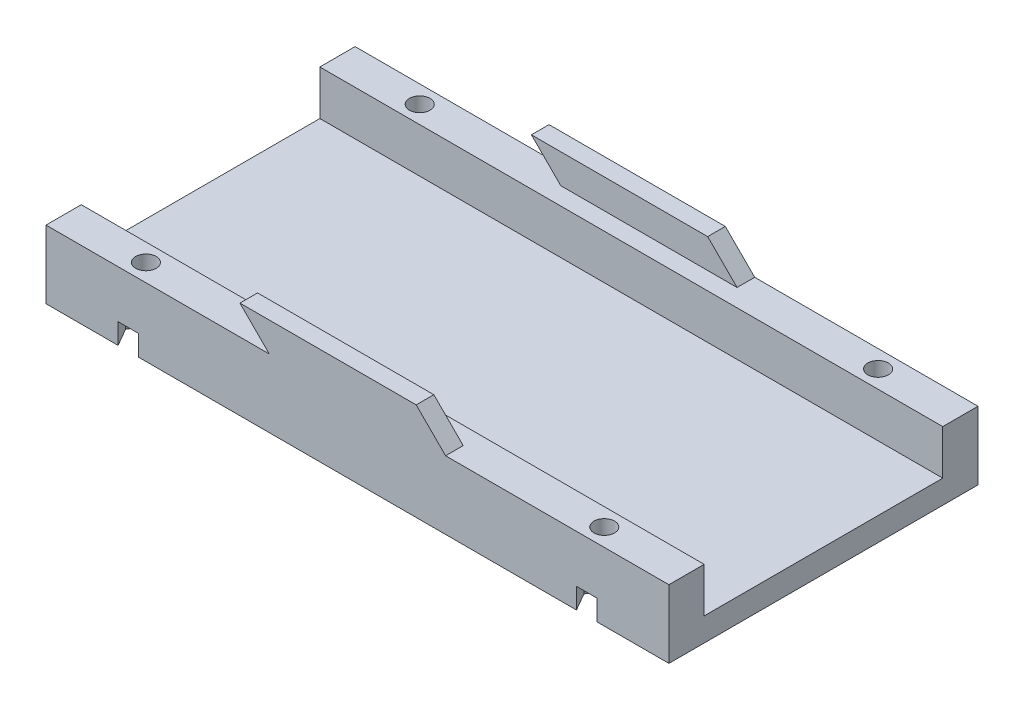
from build123d import *

# Parameters (mm, degrees)
SKETCH1_W           = 106
SKETCH1_H           = 6
SKETCH1_H_2         = 9.4
SKETCH1_H_3         = 8.5
SKETCH1_H_4         = 4.8
BOSS_EXTRUDE4_DEPTH = 4
SKETCH5_W           = 106
SKETCH5_H           = 6
BOSS_EXTRUDE5_DEPTH = 7.6
SKETCH4_W           = 106
SKETCH4_H           = 6
BOSS_EXTRUDE6_DEPTH = 7.6
SKETCH6_R           = 1.75
CUT_EXTRUDE1_DEPTH  = 20
CUT_EXTRUDE3_DEPTH  = 3.5
BOSS_EXTRUDE8_DEPTH = 3
BOSS_EXTRUDE9_DEPTH = 3


with BuildPart() as part:
    # Sketch1 → Boss-Extrude4 (new body)
    with BuildSketch(Plane(origin=(0, 0, 0), x_dir=(1, 0, 0), z_dir=(0, 1, 0))):
        with Locations((53, 20.9)):
            Rectangle(SKETCH1_W, SKETCH1_H)
        with Locations((53, 13.2)):
            Rectangle(SKETCH1_W, SKETCH1_H_2)
        with Locations((53, 4.25)):
            Rectangle(SKETCH1_W, SKETCH1_H_3)
        with Locations((53, -2.4)):
            Rectangle(SKETCH1_W, SKETCH1_H_4)
        with Locations((53, -9.05)):
            Rectangle(SKETCH1_W, SKETCH1_H_3)
        with Locations((53, -18)):
            Rectangle(SKETCH1_W, SKETCH1_H_2)
        with Locations((53, -25.7)):
            Rectangle(SKETCH1_W, SKETCH1_H)
    extrude(amount=BOSS_EXTRUDE4_DEPTH)

    # Sketch5 → Boss-Extrude5 (add)
    with BuildSketch(Plane(origin=(0, 4, 0), x_dir=(1, 0, 0), z_dir=(0, 1, 0))):
        with Locations((53, 20.9)):
            Rectangle(SKETCH5_W, SKETCH5_H)
        with Locations((53, -25.7)):
            Rectangle(SKETCH5_W, SKETCH5_H)
    extrude(amount=BOSS_EXTRUDE5_DEPTH)

    # Sketch4 → Boss-Extrude6 (add)
    with BuildSketch(Plane(origin=(0, 4, 0), x_dir=(1, 0, 0), z_dir=(0, 1, 0))):
        with Locations((53, 20.9)):
            Rectangle(SKETCH4_W, SKETCH4_H)
        with Locations((53, -25.7)):
            Rectangle(SKETCH4_W, SKETCH4_H)
    extrude(amount=BOSS_EXTRUDE6_DEPTH)

    # Sketch6 → Cut-Extrude1 (cut)
    with BuildSketch(Plane(origin=(0, 11.6, 0), x_dir=(1, 0, 0), z_dir=(0, 1, 0))):
        with Locations((92, 20.9)):
            Circle(SKETCH6_R)
        with Locations((92, -25.7)):
            Circle(SKETCH6_R)
        with Locations((14, 20.9)):
            Circle(SKETCH6_R)
        with Locations((14, -25.7)):
            Circle(SKETCH6_R)
    extrude(amount=-CUT_EXTRUDE1_DEPTH, mode=Mode.SUBTRACT)

    # Sketch7 → Cut-Extrude3 (cut)
    with BuildSketch(Plane.XZ):
        Polygon((17.464101615, 25.7), (15.732050808, 28.7), (12.267949192, 28.7), (10.535898385, 25.7), (12.267949192, 22.7), (15.732050808, 22.7), align=None)
        Polygon((95.464101615, 25.7), (93.732050808, 28.7), (90.267949192, 28.7), (88.535898385, 25.7), (90.267949192, 22.7), (93.732050808, 22.7), align=None)
        Polygon((17.464101615, -20.9), (15.732050808, -17.9), (12.267949192, -17.9), (10.535898385, -20.9), (12.267949192, -23.9), (15.732050808, -23.9), align=None)
        Polygon((95.464101615, -20.9), (93.732050808, -17.9), (90.267949192, -17.9), (88.535898385, -20.9), (90.267949192, -23.9), (93.732050808, -23.9), align=None)
    extrude(amount=-CUT_EXTRUDE3_DEPTH, mode=Mode.SUBTRACT)

    # Sketch8 → Boss-Extrude8 (add)
    with BuildSketch(Plane.XY.offset(28.7)):
        Polygon((38, 11.6), (33, 16.6), (63, 16.6), (68, 11.6), align=None)
    extrude(amount=-BOSS_EXTRUDE8_DEPTH)

    # Sketch9 → Boss-Extrude9 (add)
    with BuildSketch(Plane(origin=(0, 0, -23.9), x_dir=(-1, 0, 0), z_dir=(0, 0, -1))):
        Polygon((-68, 11.6), (-63, 16.6), (-33, 16.6), (-38, 11.6), align=None)
    extrude(amount=-BOSS_EXTRUDE9_DEPTH)


solid = part.part
